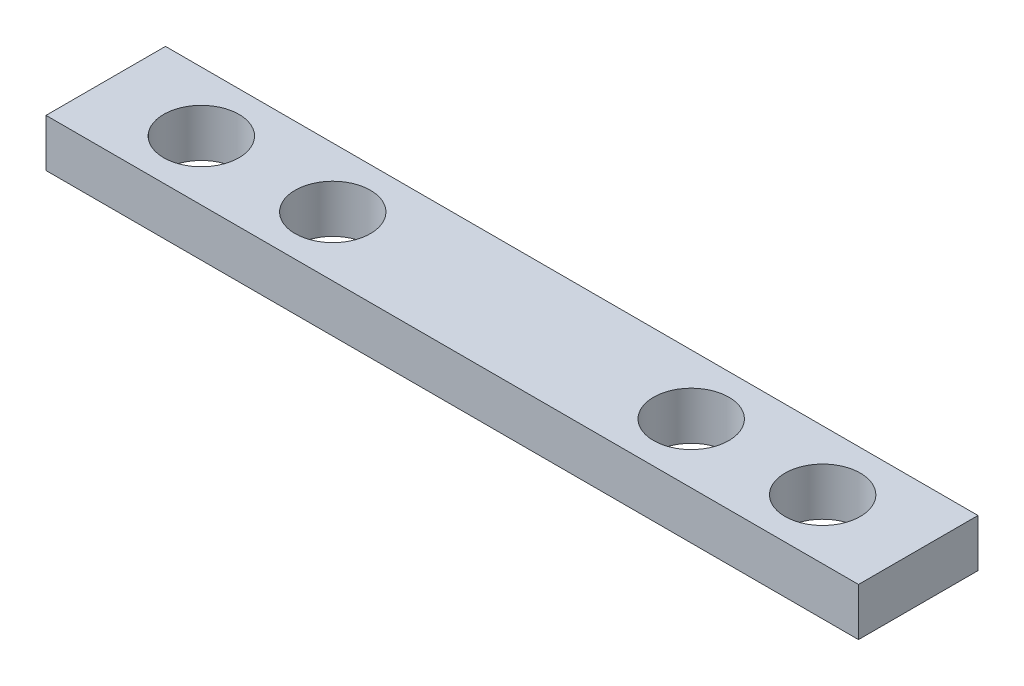
from build123d import *

# Parameters (mm, degrees)
SKETCH1_W           = 34
SKETCH1_H           = 5
BOSS_EXTRUDE2_DEPTH = 2
SKETCH4_R           = 1.575
CUT_EXTRUDE3_DEPTH  = 2
SKETCH5_R           = 1.575
CUT_EXTRUDE4_DEPTH  = 2


with BuildPart() as part:
    # Sketch1 → Boss-Extrude2 (new body)
    with BuildSketch(Plane(origin=(0, 0, 0), x_dir=(1, 0, 0), z_dir=(0, 1, 0))):
        Rectangle(SKETCH1_W, SKETCH1_H)
    extrude(amount=BOSS_EXTRUDE2_DEPTH)

    # Sketch4 → Cut-Extrude3 (cut)
    with BuildSketch(Plane(origin=(0, 2, 0), x_dir=(1, 0, 0), z_dir=(0, 1, 0))):
        with Locations((-13, 0)):
            Circle(SKETCH4_R)
        with Locations((13, 0)):
            Circle(SKETCH4_R)
    extrude(amount=-CUT_EXTRUDE3_DEPTH, mode=Mode.SUBTRACT)

    # Sketch5 → Cut-Extrude4 (cut)
    with BuildSketch(Plane(origin=(0, 2, 0), x_dir=(1, 0, 0), z_dir=(0, 1, 0))):
        with Locations((-7.5, 0)):
            Circle(SKETCH5_R)
        with Locations((7.5, 0)):
            Circle(SKETCH5_R)
    extrude(amount=-CUT_EXTRUDE4_DEPTH, mode=Mode.SUBTRACT)


solid = part.part
